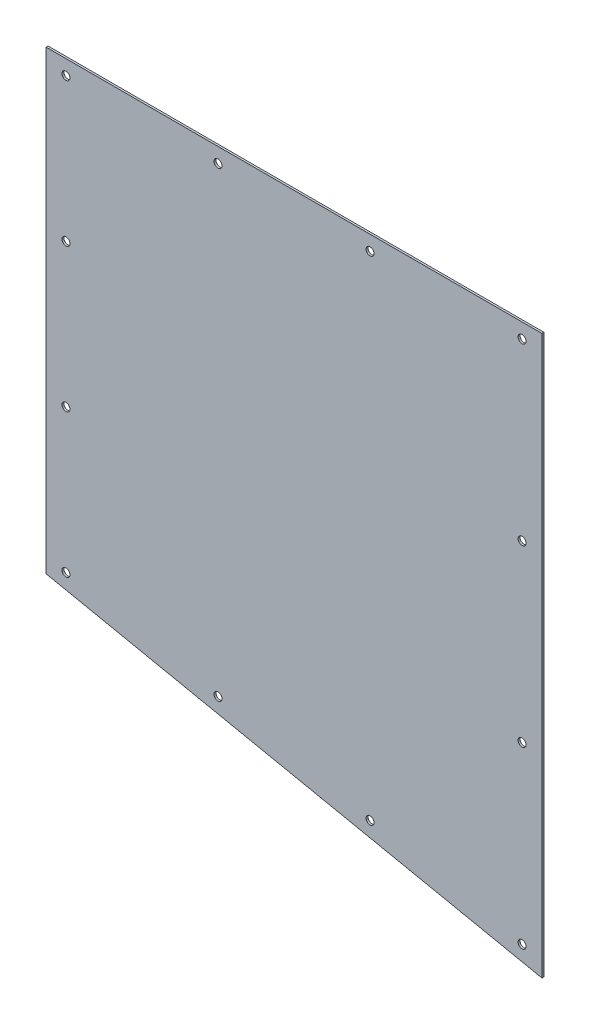
from build123d import *

# Parameters (mm, degrees)
BOSS_EXTRU_1_DEPTH      = 2
ESQUISSE3_R             = 4
ENL_V_MAT_EXTRU_1_DEPTH = 10


with BuildPart() as part:
    # Esquisse1 → Boss.-Extru.1 (new body)
    with BuildSketch(Plane.XY):
        Polygon((-250, 0), (250, 0), (250, -563), (-250, -460), align=None)
    extrude(amount=BOSS_EXTRU_1_DEPTH)

    # Esquisse3 → Enlèv. mat.-Extru.1 (cut)
    with BuildSketch(Plane(origin=(0, 0, 0), x_dir=(-1, 0, 0), z_dir=(0, 0, -1))):
        with Locations((-230, -15)):
            Circle(ESQUISSE3_R)
        with Locations((-76.666666667, -15)):
            Circle(ESQUISSE3_R)
        with Locations((76.666666667, -15)):
            Circle(ESQUISSE3_R)
        with Locations((230, -15)):
            Circle(ESQUISSE3_R)
        with Locations((230, -159.60167891)):
            Circle(ESQUISSE3_R)
        with Locations((230, -304.203357819)):
            Circle(ESQUISSE3_R)
        with Locations((76.666666667, -480.391703395)):
            Circle(ESQUISSE3_R)
        with Locations((-76.666666667, -511.978370062)):
            Circle(ESQUISSE3_R)
        with Locations((-230, -543.565036729)):
            Circle(ESQUISSE3_R)
        with Locations((-230, -367.376691152)):
            Circle(ESQUISSE3_R)
        with Locations((-230, -191.188345576)):
            Circle(ESQUISSE3_R)
        with Locations((230, -448.805036729)):
            Circle(ESQUISSE3_R)
    extrude(amount=-ENL_V_MAT_EXTRU_1_DEPTH, mode=Mode.SUBTRACT)


solid = part.part
